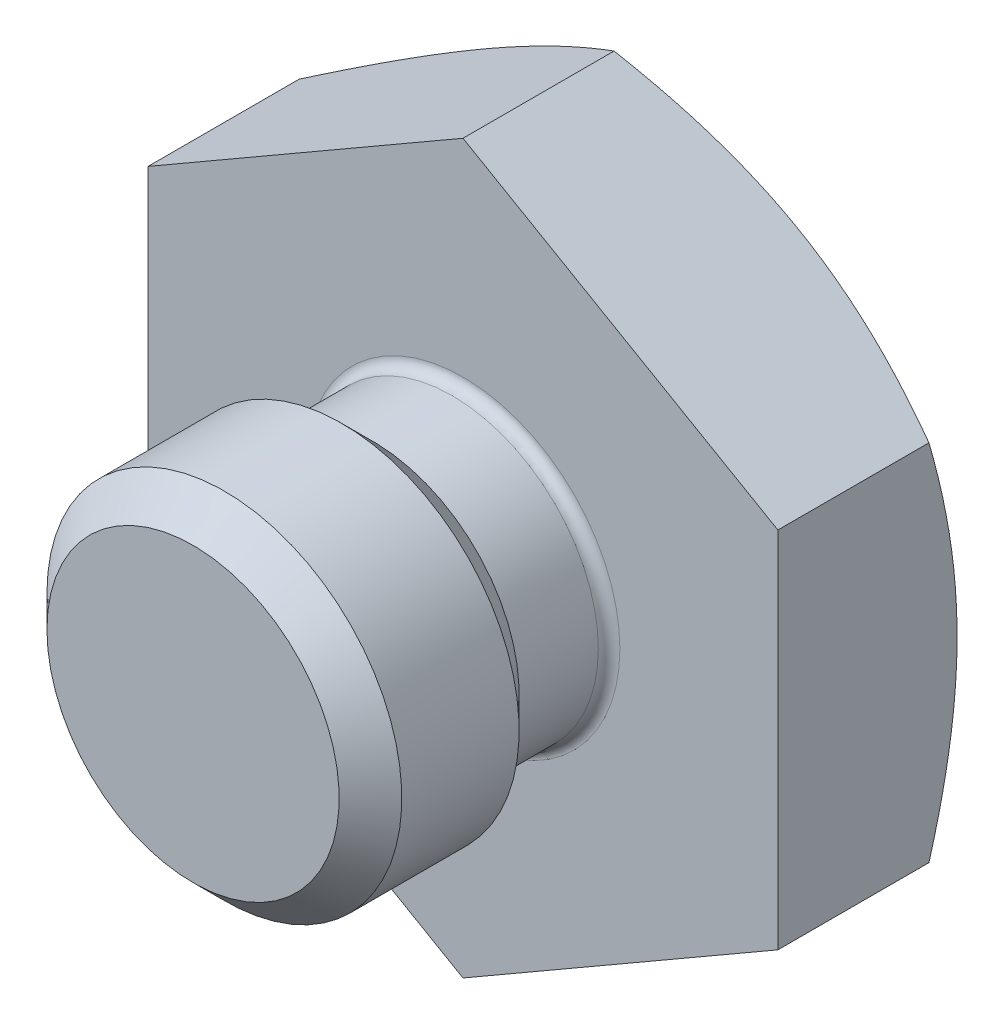
from build123d import *

# Parameters (mm, degrees)
SKETCH2_OUTSIDE_W  = 59.38
SKETCH2_OUTSIDE_H  = 59.38
CUT_EXTRUDE1_DEPTH = 13.7
FILLET1_R          = 0.381


with BuildPart() as part:
    # Sketch1 → Revolve1 (revolve)
    with BuildSketch(Plane(origin=(0, 0, 0), x_dir=(0, 0, -1), z_dir=(1, 0, 0)), mode=Mode.PRIVATE) as revolve1_sk:
        with BuildLine():
            Line((0, 22.065104351), (0, 5.1562))
            Line((0, 5.1562), (-3.175, 5.1562))
            Line((-3.175, 5.1562), (-4.2799, 6.2611))
            Line((-4.2799, 6.2611), (-8.4201, 6.2611))
            Line((-8.4201, 6.2611), (-9.525, 5.1562))
            Line((-9.525, 5.1562), (-9.525, 0))
            Line((-9.525, 0), (12.7, 0))
            ThreePointArc((12.7, 0), (12.69134516, 0.065740037), (12.665970453, 0.127))
            Line((12.665970453, 0.127), (0, 22.065104351))
        make_face()
    revolve(revolve1_sk.sketch.rotate(Axis((0, 0, 0), (0, 0, 1)), 90), axis=Axis((0, 0, 0), (0, 0, 1)))  # turned: the seam where the file's is

    # Sketch2 outside → Cut-Extrude1 (cut, through all)
    with BuildSketch(Plane.XY):
        Rectangle(SKETCH2_OUTSIDE_W, SKETCH2_OUTSIDE_H)
        Polygon((0, 12.831609733), (-11.1125, 6.415804866), (-11.1125, -6.415804866), (0, -12.831609733), (11.1125, -6.415804866), (11.1125, 6.415804866), align=None, mode=Mode.SUBTRACT)
    extrude(amount=-CUT_EXTRUDE1_DEPTH, mode=Mode.SUBTRACT)

    # Fillet1
    fillet1_edges = [part.edges().sort_by_distance(p)[0] for p in [
        (5.1562, 0, 0),
    ]]
    fillet(fillet1_edges, radius=FILLET1_R)


solid = part.part
